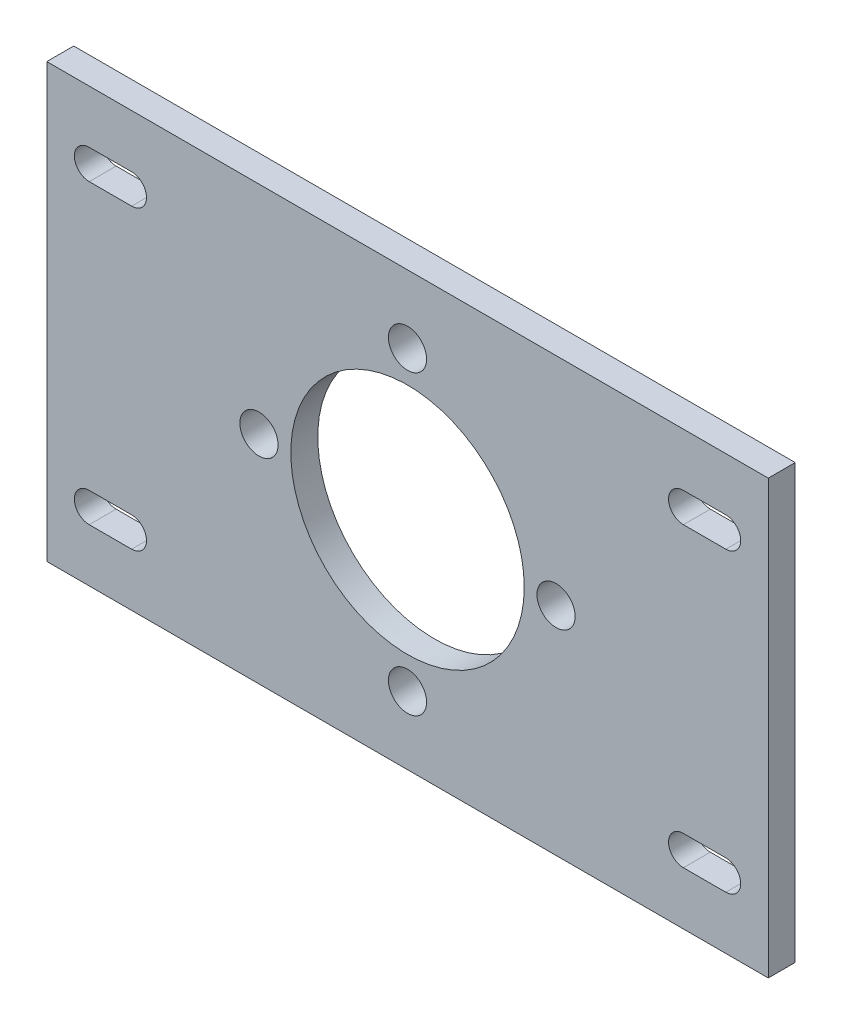
from build123d import *

# Parameters (mm, degrees)
SKETCH1_W           = 85
SKETCH1_H           = 51
SKETCH1_R           = 13.75
SKETCH1_R_2         = 2.25
BOSS_EXTRUDE1_DEPTH = 3.175


with BuildPart() as part:
    # Sketch1 → Boss-Extrude1 (new body)
    with BuildSketch(Plane.XY):
        Rectangle(SKETCH1_W, SKETCH1_H)
        Circle(SKETCH1_R, mode=Mode.SUBTRACT)
        with Locations((0, 17.5)):
            Circle(SKETCH1_R_2, mode=Mode.SUBTRACT)
        with Locations((17.5, 0)):
            Circle(SKETCH1_R_2, mode=Mode.SUBTRACT)
        with Locations((0, -17.5)):
            Circle(SKETCH1_R_2, mode=Mode.SUBTRACT)
        with Locations((-17.5, 0)):
            Circle(SKETCH1_R_2, mode=Mode.SUBTRACT)
        with BuildLine():
            Line((-37.5, 19.25), (-32.5, 19.25))
            ThreePointArc((-32.5, 19.25), (-30.75, 17.5), (-32.5, 15.75))
            Line((-32.5, 15.75), (-37.5, 15.75))
            ThreePointArc((-37.5, 15.75), (-39.25, 17.5), (-37.5, 19.25))
        make_face(mode=Mode.SUBTRACT)
        with BuildLine():
            Line((37.5, 19.25), (32.5, 19.25))
            ThreePointArc((32.5, 19.25), (30.75, 17.5), (32.5, 15.75))
            Line((32.5, 15.75), (37.5, 15.75))
            ThreePointArc((37.5, 15.75), (39.25, 17.5), (37.5, 19.25))
        make_face(mode=Mode.SUBTRACT)
        with BuildLine():
            Line((37.5, -19.25), (32.5, -19.25))
            ThreePointArc((32.5, -19.25), (30.75, -17.5), (32.5, -15.75))
            Line((32.5, -15.75), (37.5, -15.75))
            ThreePointArc((37.5, -15.75), (39.25, -17.5), (37.5, -19.25))
        make_face(mode=Mode.SUBTRACT)
        with BuildLine():
            Line((-37.5, -19.25), (-32.5, -19.25))
            ThreePointArc((-32.5, -19.25), (-30.75, -17.5), (-32.5, -15.75))
            Line((-32.5, -15.75), (-37.5, -15.75))
            ThreePointArc((-37.5, -15.75), (-39.25, -17.5), (-37.5, -19.25))
        make_face(mode=Mode.SUBTRACT)
    extrude(amount=BOSS_EXTRUDE1_DEPTH)


solid = part.part
